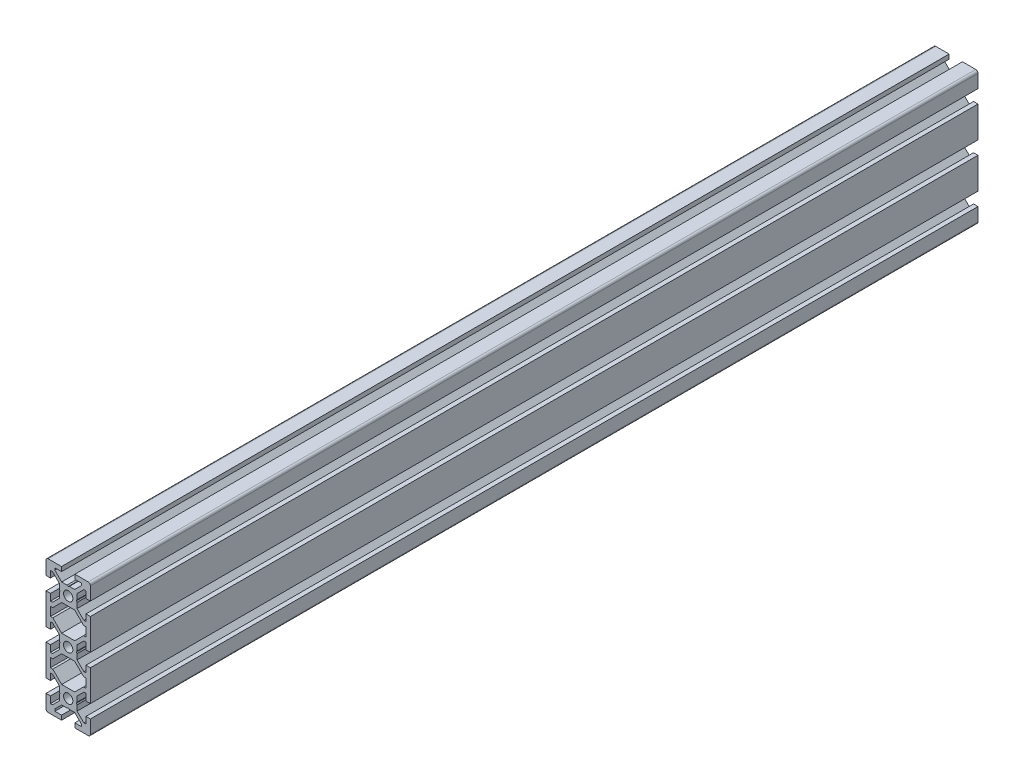
from build123d import *

# Parameters (mm, degrees)
SKETCH1_R                 = 2.1
BOSS_EXTRUDE1_DEPTH       = 400
M5X0_8_TAPPED_HOLE1_D     = 4.2
M5X0_8_TAPPED_HOLE1_DEPTH = 14
M5X0_8_TAPPED_HOLE1_TIP   = 1.2618073
M5X0_8_TAPPED_HOLE2_D     = 4.2
M5X0_8_TAPPED_HOLE2_DEPTH = 14
M5X0_8_TAPPED_HOLE2_TIP   = 1.2618073


with BuildPart() as part:
    # Sketch1 → Boss-Extrude1 (new body)
    with BuildSketch(Plane(origin=(0, 0, -400), x_dir=(-1, 0, 0), z_dir=(0, 0, -1))):
        with BuildLine():
            Line((10, -17), (10, -3))
            Line((10, -3), (8, -3))
            Line((8, -3), (8, -6))
            Line((8, -6), (7.060660172, -6))
            Line((7.060660172, -6), (4, -2.939339828))
            Line((4, -2.939339828), (4, -0.519615242))
            Line((4, -0.519615242), (3.7, 0))
            Line((3.7, 0), (4, 0.519615242))
            Line((4, 0.519615242), (4, 2.939339828))
            Line((4, 2.939339828), (7.060660172, 6))
            Line((7.060660172, 6), (8, 6))
            Line((8, 6), (8, 3))
            Line((8, 3), (10, 3))
            Line((10, 3), (10, 17))
            Line((10, 17), (8, 17))
            Line((8, 17), (8, 14))
            Line((8, 14), (7.060660172, 14))
            Line((7.060660172, 14), (4, 17.060660172))
            Line((4, 17.060660172), (4, 19.480384758))
            Line((4, 19.480384758), (3.7, 20))
            Line((3.7, 20), (4, 20.519615242))
            Line((4, 20.519615242), (4, 22.939339828))
            Line((4, 22.939339828), (7.060660172, 26))
            Line((7.060660172, 26), (8, 26))
            Line((8, 26), (8, 23))
            Line((8, 23), (10, 23))
            Line((10, 23), (10, 29))
            ThreePointArc((10, 29), (9.707106781, 29.707106781), (9, 30))
            Line((9, 30), (3, 30))
            Line((3, 30), (3, 28))
            Line((3, 28), (6, 28))
            Line((6, 28), (6, 27.060660172))
            Line((6, 27.060660172), (2.939339828, 24))
            Line((2.939339828, 24), (0.519615242, 24))
            Line((0.519615242, 24), (0, 23.7))
            Line((0, 23.7), (-0.519615242, 24))
            Line((-0.519615242, 24), (-2.939339828, 24))
            Line((-2.939339828, 24), (-6, 27.060660172))
            Line((-6, 27.060660172), (-6, 28))
            Line((-6, 28), (-3, 28))
            Line((-3, 28), (-3, 30))
            Line((-3, 30), (-9, 30))
            ThreePointArc((-9, 30), (-9.707106781, 29.707106781), (-10, 29))
            Line((-10, 29), (-10, 23))
            Line((-10, 23), (-8, 23))
            Line((-8, 23), (-8, 26))
            Line((-8, 26), (-7.060660172, 26))
            Line((-7.060660172, 26), (-4, 22.939339828))
            Line((-4, 22.939339828), (-4, 20.519615242))
            Line((-4, 20.519615242), (-3.7, 20))
            Line((-3.7, 20), (-4, 19.480384758))
            Line((-4, 19.480384758), (-4, 17.060660172))
            Line((-4, 17.060660172), (-7.060660172, 14))
            Line((-7.060660172, 14), (-8, 14))
            Line((-8, 14), (-8, 17))
            Line((-8, 17), (-10, 17))
            Line((-10, 17), (-10, 3))
            Line((-10, 3), (-8, 3))
            Line((-8, 3), (-8, 6))
            Line((-8, 6), (-7.060660172, 6))
            Line((-7.060660172, 6), (-4, 2.939339828))
            Line((-4, 2.939339828), (-4, 0.519615242))
            Line((-4, 0.519615242), (-3.7, 0))
            Line((-3.7, 0), (-4, -0.519615242))
            Line((-4, -0.519615242), (-4, -2.939339828))
            Line((-4, -2.939339828), (-7.060660172, -6))
            Line((-7.060660172, -6), (-8, -6))
            Line((-8, -6), (-8, -3))
            Line((-8, -3), (-10, -3))
            Line((-10, -3), (-10, -17))
            Line((-10, -17), (-8, -17))
            Line((-8, -17), (-8, -14))
            Line((-8, -14), (-7.060660172, -14))
            Line((-7.060660172, -14), (-4, -17.060660172))
            Line((-4, -17.060660172), (-4, -19.480384758))
            Line((-4, -19.480384758), (-3.7, -20))
            Line((-3.7, -20), (-4, -20.519615242))
            Line((-4, -20.519615242), (-4, -22.939339828))
            Line((-4, -22.939339828), (-7.060660172, -26))
            Line((-7.060660172, -26), (-8, -26))
            Line((-8, -26), (-8, -23))
            Line((-8, -23), (-10, -23))
            Line((-10, -23), (-10, -29))
            ThreePointArc((-10, -29), (-9.707106781, -29.707106781), (-9, -30))
            Line((-9, -30), (-3, -30))
            Line((-3, -30), (-3, -28))
            Line((-3, -28), (-6, -28))
            Line((-6, -28), (-6, -27.060660172))
            Line((-6, -27.060660172), (-2.939339828, -24))
            Line((-2.939339828, -24), (-0.519615242, -24))
            Line((-0.519615242, -24), (0, -23.7))
            Line((0, -23.7), (0.519615242, -24))
            Line((0.519615242, -24), (2.939339828, -24))
            Line((2.939339828, -24), (6, -27.060660172))
            Line((6, -27.060660172), (6, -28))
            Line((6, -28), (3, -28))
            Line((3, -28), (3, -30))
            Line((3, -30), (9, -30))
            ThreePointArc((9, -30), (9.707106781, -29.707106781), (10, -29))
            Line((10, -29), (10, -23))
            Line((10, -23), (8, -23))
            Line((8, -23), (8, -26))
            Line((8, -26), (7.060660172, -26))
            Line((7.060660172, -26), (4, -22.939339828))
            Line((4, -22.939339828), (4, -20.519615242))
            Line((4, -20.519615242), (3.7, -20))
            Line((3.7, -20), (4, -19.480384758))
            Line((4, -19.480384758), (4, -17.060660172))
            Line((4, -17.060660172), (7.060660172, -14))
            Line((7.060660172, -14), (8, -14))
            Line((8, -14), (8, -17))
            Line((8, -17), (10, -17))
        make_face()
        Circle(SKETCH1_R, mode=Mode.SUBTRACT)
        with Locations((0, -20)):
            Circle(SKETCH1_R, mode=Mode.SUBTRACT)
        with Locations((0, 20)):
            Circle(SKETCH1_R, mode=Mode.SUBTRACT)
        Polygon((6.939339828, -8), (8, -8), (8, -12), (6.939339828, -12), (2.939339828, -16), (-2.939339828, -16), (-6.939339828, -12), (-8, -12), (-8, -8), (-6.939339828, -8), (-2.939339828, -4), (2.939339828, -4), align=None, mode=Mode.SUBTRACT)
        Polygon((8, 12), (8, 8), (6.939339828, 8), (2.939339828, 4), (-2.939339828, 4), (-6.939339828, 8), (-8, 8), (-8, 12), (-6.939339828, 12), (-2.939339828, 16), (2.939339828, 16), (6.939339828, 12), align=None, mode=Mode.SUBTRACT)
    extrude(amount=-BOSS_EXTRUDE1_DEPTH)

    # M5x0.8 Tapped Hole1
    with Locations(Plane.XY):
        with Locations((0, 20), (0, 0), (0, -20)):
            Hole(M5X0_8_TAPPED_HOLE1_D / 2, depth=M5X0_8_TAPPED_HOLE1_DEPTH)
            with Locations((0, 0, -(M5X0_8_TAPPED_HOLE1_DEPTH + M5X0_8_TAPPED_HOLE1_TIP / 2))):  # 118° drill point
                Cone(0, M5X0_8_TAPPED_HOLE1_D / 2, M5X0_8_TAPPED_HOLE1_TIP, mode=Mode.SUBTRACT)

    # M5x0.8 Tapped Hole2
    with Locations(Plane(origin=(0, 0, -400), x_dir=(-1, 0, 0), z_dir=(0, 0, -1))):
        with Locations((0, -20), (0, 0), (0, 20)):
            Hole(M5X0_8_TAPPED_HOLE2_D / 2, depth=M5X0_8_TAPPED_HOLE2_DEPTH)
            with Locations((0, 0, -(M5X0_8_TAPPED_HOLE2_DEPTH + M5X0_8_TAPPED_HOLE2_TIP / 2))):  # 118° drill point
                Cone(0, M5X0_8_TAPPED_HOLE2_D / 2, M5X0_8_TAPPED_HOLE2_TIP, mode=Mode.SUBTRACT)


solid = part.part
